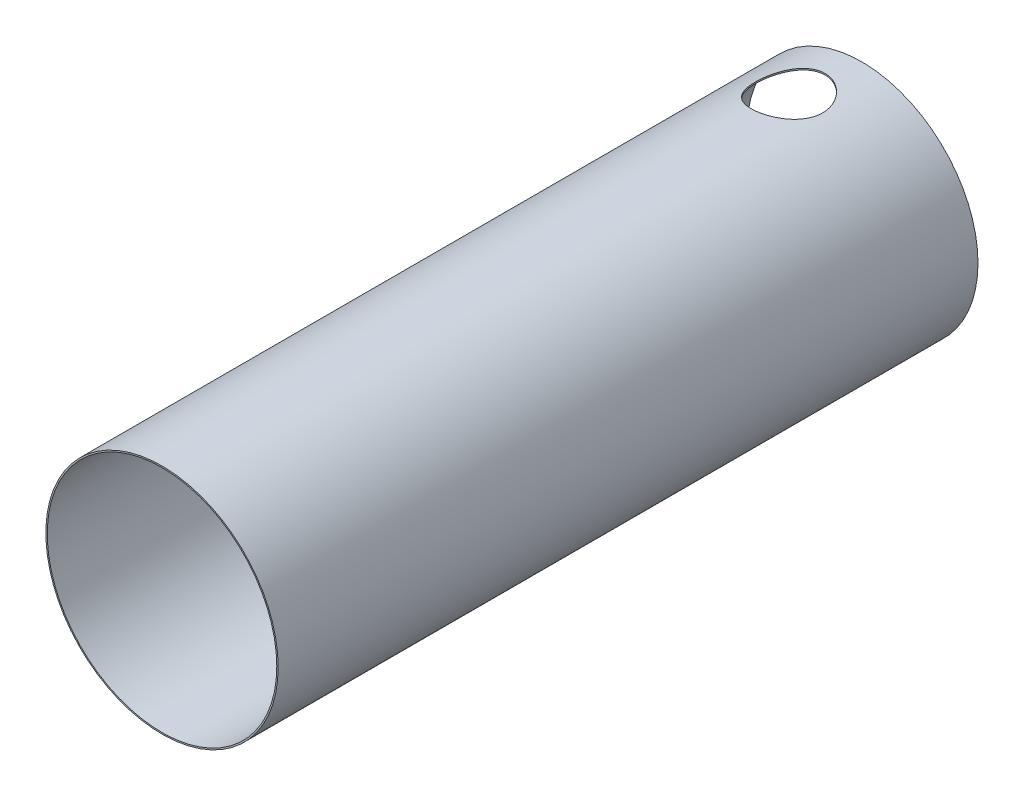
from build123d import *

# Parameters (mm, degrees)
SKETCH1_R          = 20.75
SKETCH1_R_2        = 20.5
EXTRUDE1_DEPTH     = 125
SKETCH2_R          = 6
CUT_EXTRUDE1_DEPTH = 21.75


with BuildPart() as part:
    # Sketch1 → Extrude1 (new body)
    with BuildSketch(Plane.XY):
        Circle(SKETCH1_R)
        Circle(SKETCH1_R_2, mode=Mode.SUBTRACT)
    extrude(amount=EXTRUDE1_DEPTH)

    # Sketch2 → Cut-Extrude1 (cut, through all)
    with BuildSketch(Plane(origin=(0, 0, 0), x_dir=(1, 0, 0), z_dir=(0, 1, 0))):
        with Locations(Location((-2, -11, 0), (0, 0, 90))):  # turned: the seam where the file's is
            Circle(SKETCH2_R)
    extrude(amount=CUT_EXTRUDE1_DEPTH, mode=Mode.SUBTRACT)


solid = part.part
